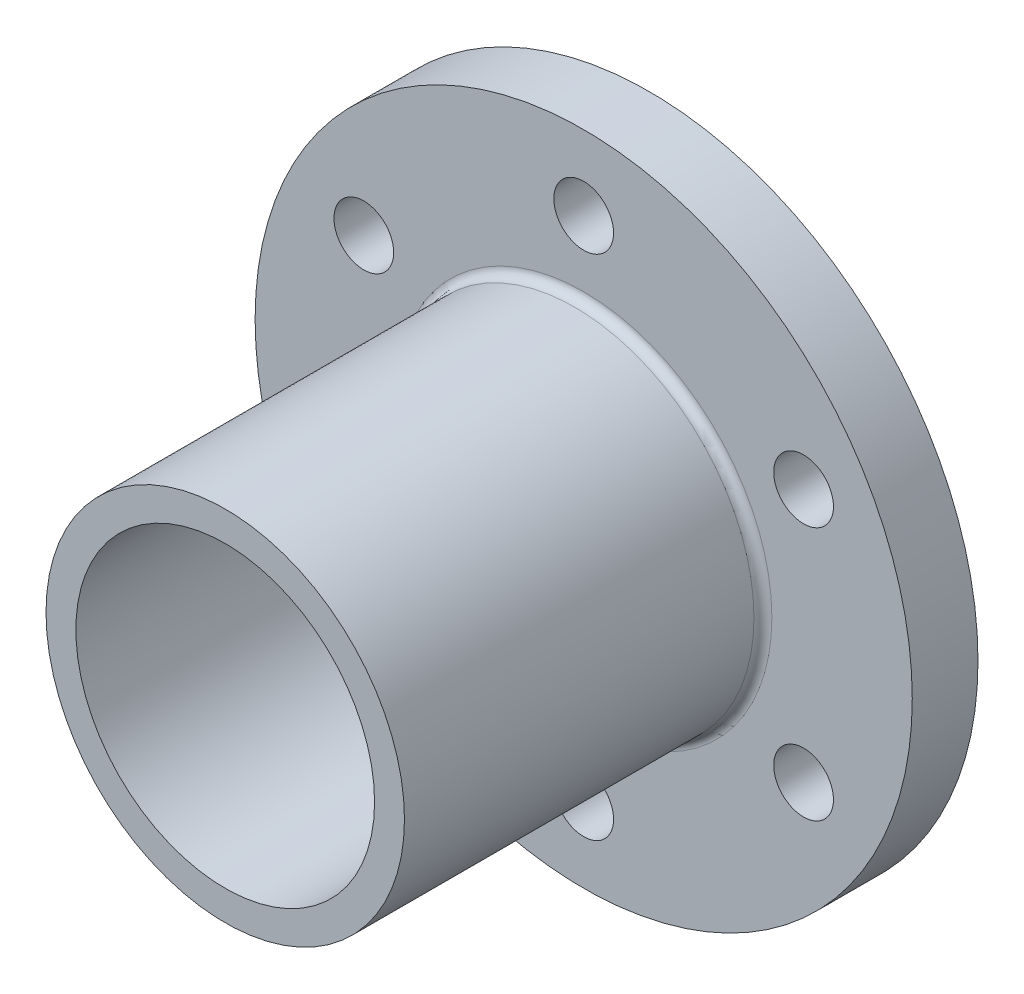
from build123d import *

# Parameters (mm, degrees)
SKETCH1_R           = 110
BOSS_EXTRUDE1_DEPTH = 22
SKETCH2_R           = 60
BOSS_EXTRUDE2_DEPTH = 120
SKETCH3_R           = 50
CUT_EXTRUDE1_DEPTH  = 143
SKETCH4_R           = 10
CUT_EXTRUDE2_DEPTH  = 23
FILLET1_R           = 3


with BuildPart() as part:
    # Sketch1 → Boss-Extrude1 (new body)
    with BuildSketch(Plane.XY):
        Circle(SKETCH1_R)
    extrude(amount=BOSS_EXTRUDE1_DEPTH)

    # Sketch2 → Boss-Extrude2 (add)
    with BuildSketch(Plane.XY.offset(22)):
        Circle(SKETCH2_R)
    extrude(amount=BOSS_EXTRUDE2_DEPTH)

    # Sketch3 → Cut-Extrude1 (cut, through all)
    with BuildSketch(Plane.XY.offset(142)):
        Circle(SKETCH3_R)
    extrude(amount=-CUT_EXTRUDE1_DEPTH, mode=Mode.SUBTRACT)

    # Sketch4 → Cut-Extrude2 (cut, through all)
    with BuildSketch(Plane.XY.offset(22)):
        with Locations((0, 85)):
            Circle(SKETCH4_R)
        with Locations((73.612159322, 42.5)):
            Circle(SKETCH4_R)
        with Locations((73.612159322, -42.5)):
            Circle(SKETCH4_R)
        with Locations((0, -85)):
            Circle(SKETCH4_R)
        with Locations((-73.612159322, -42.5)):
            Circle(SKETCH4_R)
        with Locations((-73.612159322, 42.5)):
            Circle(SKETCH4_R)
    extrude(amount=-CUT_EXTRUDE2_DEPTH, mode=Mode.SUBTRACT)

    # Fillet1
    fillet1_edges = [part.edges().sort_by_distance(p)[0] for p in [
        (-60, 0, 22),
    ]]
    fillet(fillet1_edges, radius=FILLET1_R)


solid = part.part
